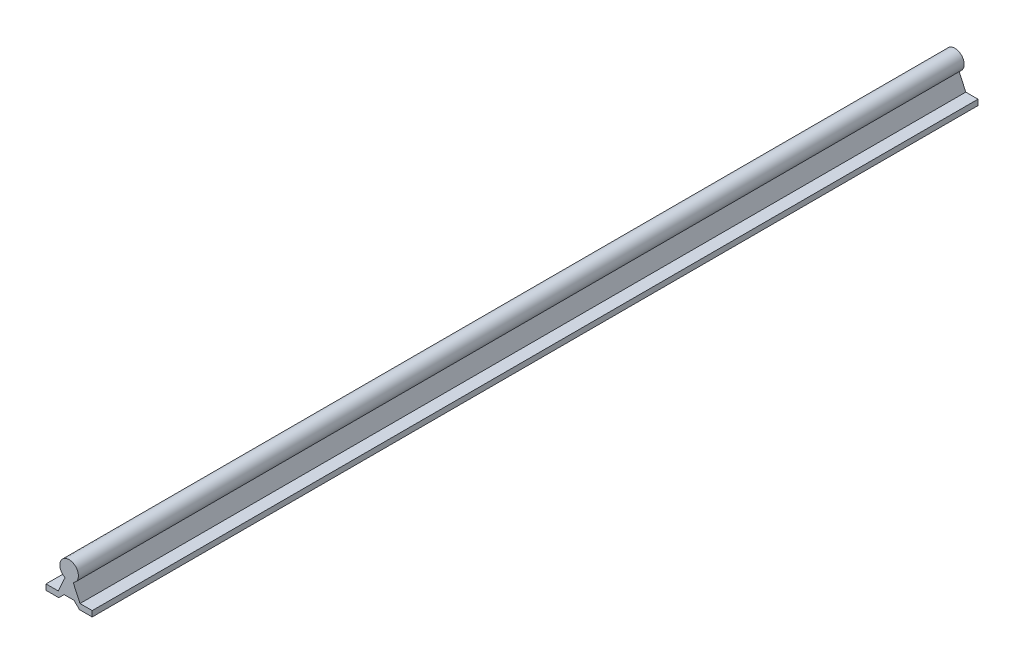
from build123d import *

# Parameters (mm, degrees)
BOSS_EXTRUDE1_DEPTH = 762


with BuildPart() as part:
    # Sketch1 → Boss-Extrude1 (new body)
    with BuildSketch(Plane.XY):
        with BuildLine():
            Line((3.5, 17.606252715), (9.375, 4.8))
            Line((9.375, 4.8), (19.875, 4.8))
            Line((19.875, 4.8), (19.875, 0))
            Line((19.875, 0), (8.875, 0))
            Line((8.875, 0), (4.275, 4.6))
            Line((4.275, 4.6), (-4.275, 4.6))
            Line((-4.275, 4.6), (-8.875, 0))
            Line((-8.875, 0), (-19.875, 0))
            Line((-19.875, 0), (-19.875, 4.8))
            Line((-19.875, 4.8), (-9.375, 4.8))
            Line((-9.375, 4.8), (-3.5, 17.606252715))
            ThreePointArc((-3.5, 17.606252715), (0, 32.8), (3.5, 17.606252715))
        make_face()
    extrude(amount=BOSS_EXTRUDE1_DEPTH)


solid = part.part
